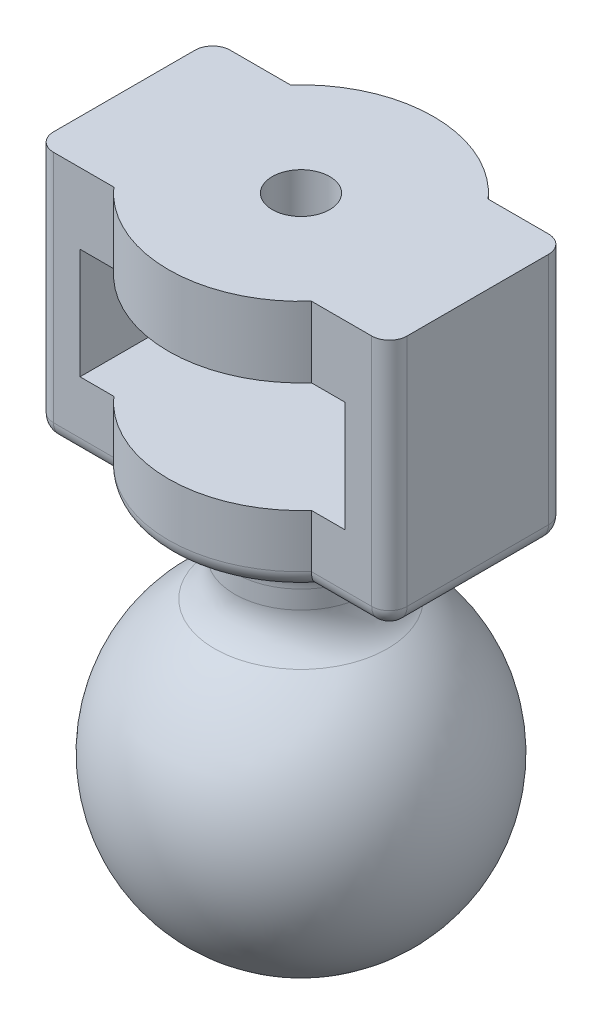
from build123d import *

# Parameters (mm, degrees)
SKETCH1_R           = 3.25
BOSS_EXTRUDE1_DEPTH = 8
BOSS_EXTRUDE2_DEPTH = 12.5
BOSS_EXTRUDE3_START = -12.5
BOSS_EXTRUDE3_DEPTH = 8
SKETCH2_R           = 7.5
BOSS_EXTRUDE4_DEPTH = 10
FILLET2_R           = 2
FILLET3_R           = 5


with BuildPart() as part:
    # Sketch1 → Boss-Extrude1 (new body)
    with BuildSketch(Plane(origin=(0, 0, 0), x_dir=(1, 0, 0), z_dir=(0, 1, 0))):
        with BuildLine():
            Line((-20, 10), (-20, -10))
            Line((-20, -10), (-11.180339887, -10))
            ThreePointArc((-11.180339887, -10), (0, -15), (11.180339887, -10))
            Line((11.180339887, -10), (20, -10))
            Line((20, -10), (20, 10))
            Line((20, 10), (11.180339887, 10))
            ThreePointArc((11.180339887, 10), (0, 15), (-11.180339887, 10))
            Line((-11.180339887, 10), (-20, 10))
        make_face()
        with Locations(Location((0, 0, 0), (0, 0, 270))):
            Circle(SKETCH1_R, mode=Mode.SUBTRACT)
    extrude(amount=BOSS_EXTRUDE1_DEPTH)

    # Sketch1_3 → Boss-Extrude2 (add)
    with BuildSketch(Plane(origin=(0, 0, 0), x_dir=(1, 0, 0), z_dir=(0, 1, 0))):
        Polygon((-15, 10), (-20, 10), (-20, -10), (-15, -10), (-15, 0), align=None)
        Polygon((20, 10), (15, 10), (15, 0), (15, -10), (20, -10), align=None)
    extrude(amount=-BOSS_EXTRUDE2_DEPTH)

    # Sketch1_4 → Boss-Extrude3 (add)
    with BuildSketch(Plane(origin=(0, 0, 0), x_dir=(1, 0, 0), z_dir=(0, 1, 0)).offset(BOSS_EXTRUDE3_START)):
        with BuildLine():
            Line((-20, 10), (-20, -10))
            Line((-20, -10), (-11.180339887, -10))
            ThreePointArc((-11.180339887, -10), (0, -15), (11.180339887, -10))
            Line((11.180339887, -10), (20, -10))
            Line((20, -10), (20, 10))
            Line((20, 10), (11.180339887, 10))
            ThreePointArc((11.180339887, 10), (0, 15), (-11.180339887, 10))
            Line((-11.180339887, 10), (-20, 10))
        make_face()
    extrude(amount=-BOSS_EXTRUDE3_DEPTH)

    # Sketch2 → Boss-Extrude4 (add)
    with BuildSketch(Plane.XZ.offset(20.5)):
        with Locations(Location((0, 0, 0), (0, 0, 270))):
            Circle(SKETCH2_R)
    extrude(amount=BOSS_EXTRUDE4_DEPTH)

    # Sketch3 → Revolve1 (revolve)
    with BuildSketch(Plane.XY):
        with BuildLine():
            ThreePointArc((0, -28.863068172), (-3.8382791, -29.277061987), (-7.5, -30.5))
            Line((-7.5, -30.5), (0, -30.5))
            Line((0, -30.5), (0, -28.863068172))
        make_face()
        with BuildLine():
            Line((0, -30.5), (-7.5, -30.5))
            ThreePointArc((-7.5, -30.5), (-17.586006185, -50.701347272), (0, -64.863068172))
            Line((0, -64.863068172), (0, -30.5))
        make_face()
    revolve(axis=Axis((0, -64.863068172, 0), (0, 1, 0)))

    # Fillet2
    fillet2_edges = [part.edges().sort_by_distance(p)[0] for p in [
        (-20, -6.25, -10),
        (-20, -6.25, 10),
        (15.590169944, -20.5, 10),
        (0, -20.5, -15),
        (0, -20.5, 15),
        (-15.590169944, -20.5, -10),
        (15.590169944, -20.5, -10),
        (20, -20.5, 0),
        (-20, -20.5, 0),
        (20, -6.25, -10),
        (-15.590169944, -20.5, 10),
        (20, -6.25, 10),
    ]]
    fillet(fillet2_edges, radius=FILLET2_R)

    # Fillet3
    fillet3_edges = [part.edges().sort_by_distance(p)[0] for p in [
        (0, -20.5, 7.5),
        (-5.303300859, -30.5, -5.303300859),
    ]]
    fillet(fillet3_edges, radius=FILLET3_R)


solid = part.part
